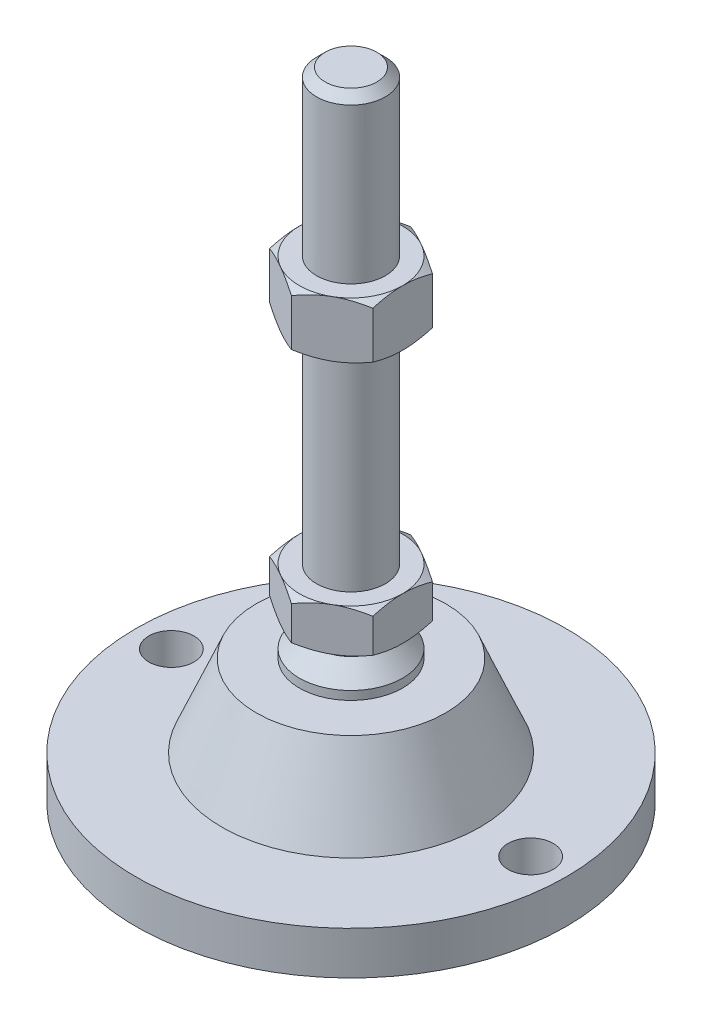
from build123d import *

# Parameters (mm, degrees)
EXTRUDE_1_DEPTH     = 10
EXTRUDE_2_DEPTH     = 13
SKETCH_5_R          = 5.25
CUT_EXTRUDE_1_DEPTH = 11


with BuildPart() as part:
    # Эскиз1 → Повернуть1 (revolve)
    with BuildSketch(Plane.XY, mode=Mode.PRIVATE) as revolve_1_sk:
        Polygon((0, 0), (-50, 0), (-50, 10), (-30, 10), (-22, 29), (-12, 29), (-12, 31), (-8, 35), (-8, 38), (-8, 48), (-8, 146), (-6, 148), (0, 148), align=None)
    revolve(revolve_1_sk.sketch.rotate(Axis((0, 0, 0), (0, 1, 0)), 180), axis=Axis((0, 0, 0), (0, 1, 0)))  # turned: the seam where the file's is

    # Эскиз2 → Бобышка-Вытянуть1 (add)
    with BuildSketch(Plane(origin=(0, 38, 0), x_dir=(1, 0, 0), z_dir=(0, 1, 0))):
        Polygon((0, 13.856406461), (-12, 6.92820323), (-12, -6.92820323), (0, -13.856406461), (12, -6.92820323), (12, 6.92820323), align=None)
    extrude(amount=EXTRUDE_1_DEPTH)

    # Эскиз3 → Бобышка-Вытянуть2 (add)
    with BuildSketch(Plane(origin=(0, 97, 0), x_dir=(1, 0, 0), z_dir=(0, 1, 0))):
        Polygon((12, 6.92820323), (0, 13.856406461), (-12, 6.92820323), (-12, -6.92820323), (0, -13.856406461), (12, -6.92820323), align=None)
    extrude(amount=EXTRUDE_2_DEPTH)

    # Эскиз4 → Вырез-Повернуть2 (revolve, cut)
    with BuildSketch(Plane.XY, mode=Mode.PRIVATE) as cut_revolve_2_sk:
        Polygon((-23.258330249, 110), (-12, 110), (-23.258330249, 103.5), align=None)
        Polygon((-23.258330249, 97), (-23.258330249, 103.5), (-12, 97), align=None)
        Polygon((-20.660254038, 48), (-20.660254038, 43), (-12, 48), align=None)
        Polygon((-20.660254038, 43), (-20.660254038, 38), (-12, 38), align=None)
    revolve(cut_revolve_2_sk.sketch.rotate(Axis((0, 148, 0), (0, -1, 0)), 180), axis=Axis((0, 148, 0), (0, -1, 0)), mode=Mode.SUBTRACT)  # turned: the seam where the file's is

    # Эскиз5 → Вырез-Вытянуть1 (cut, through all)
    with BuildSketch(Plane(origin=(0, 10, 0), x_dir=(1, 0, 0), z_dir=(0, 1, 0))):
        with Locations(Location((-41.75, 0, 0), (0, 0, 180))):  # turned: the seam where the file's is
            Circle(SKETCH_5_R)
        with Locations(Location((41.75, 0, 0), (0, 0, 180))):  # turned: the seam where the file's is
            Circle(SKETCH_5_R)
    extrude(amount=-CUT_EXTRUDE_1_DEPTH, mode=Mode.SUBTRACT)


solid = part.part
